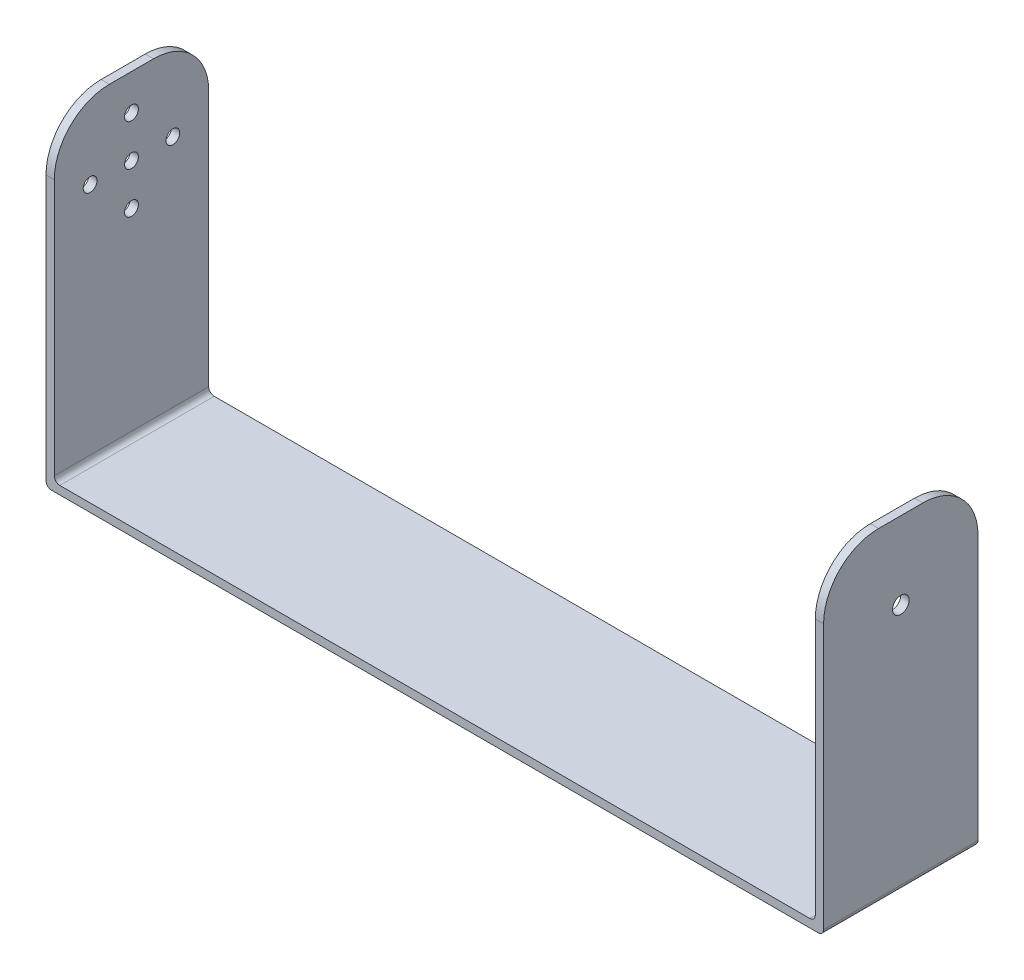
from build123d import *

# Parameters (mm, degrees)
SKETCH1_W               = 138
SKETCH1_H               = 28
BOSS_EXTRUDE1_DEPTH     = 1.5
SKETCH2_W               = 28
SKETCH2_H               = 59
BOSS_EXTRUDE2_DEPTH     = 1.5
FILLET1_R               = 1
FILLET2_R               = 1
FILLET5_R               = 10
SKETCH3_R               = 1.25
CUT_EXTRUDE1_DEPTH      = 15
CUT_EXTRUDE1_DEPTH_BACK = 15
SKETCH4_W               = 28
SKETCH4_H               = 59
BOSS_EXTRUDE3_DEPTH     = 1.5
FILLET6_R               = 1
FILLET7_R               = 1
SKETCH5_R               = 1.5
CUT_EXTRUDE3_DEPTH      = 1.5
CUT_EXTRUDE3_DEPTH_BACK = 31.5
FILLET10_R              = 10
FILLET11_R              = 10


with BuildPart() as part:
    # Sketch1 → Boss-Extrude1 (new body)
    with BuildSketch(Plane(origin=(0, 0, 0), x_dir=(1, 0, 0), z_dir=(0, 1, 0))):
        with Locations((69, 14)):
            Rectangle(SKETCH1_W, SKETCH1_H)
    extrude(amount=BOSS_EXTRUDE1_DEPTH)

    # Sketch2 → Boss-Extrude2 (add)
    with BuildSketch(Plane(origin=(0, 0, 0), x_dir=(0, 0, -1), z_dir=(1, 0, 0))):
        with Locations((14, 29.5)):
            Rectangle(SKETCH2_W, SKETCH2_H)
    extrude(amount=-BOSS_EXTRUDE2_DEPTH)

    # Fillet1
    fillet1_edges = [part.edges().sort_by_distance(p)[0] for p in [
        (0, 1.5, -14),
    ]]
    fillet(fillet1_edges, radius=FILLET1_R)

    # Fillet2
    fillet2_edges = [part.edges().sort_by_distance(p)[0] for p in [
        (-1.5, 0, -14),
    ]]
    fillet(fillet2_edges, radius=FILLET2_R)

    # Fillet5
    fillet5_edges = [part.edges().sort_by_distance(p)[0] for p in [
        (-0.75, 59, 0),
        (-0.75, 59, -28),
    ]]
    fillet(fillet5_edges, radius=FILLET5_R)

    # Sketch3 → Cut-Extrude1 (cut, two sides)
    with BuildSketch(Plane(origin=(0, 0, 0), x_dir=(0, 0, -1), z_dir=(1, 0, 0))) as cut_extrude1_sk:
        with Locations((14, 52.5)):
            Circle(SKETCH3_R)
        with Locations((6.5, 45)):
            Circle(SKETCH3_R)
        with Locations((14, 45)):
            Circle(SKETCH3_R)
        with Locations((21.5, 45)):
            Circle(SKETCH3_R)
        with Locations((14, 37.5)):
            Circle(SKETCH3_R)
    extrude(amount=CUT_EXTRUDE1_DEPTH, mode=Mode.SUBTRACT)
    extrude(cut_extrude1_sk.sketch, amount=-CUT_EXTRUDE1_DEPTH_BACK, mode=Mode.SUBTRACT)

    # Sketch4 → Boss-Extrude3 (add)
    with BuildSketch(Plane(origin=(138, 0, 0), x_dir=(0, 0, -1), z_dir=(1, 0, 0))):
        with Locations((14, 29.5)):
            Rectangle(SKETCH4_W, SKETCH4_H)
    extrude(amount=BOSS_EXTRUDE3_DEPTH)

    # Fillet6
    fillet6_edges = [part.edges().sort_by_distance(p)[0] for p in [
        (139.5, 0, -14),
    ]]
    fillet(fillet6_edges, radius=FILLET6_R)

    # Fillet7
    fillet7_edges = [part.edges().sort_by_distance(p)[0] for p in [
        (138, 1.5, -14),
    ]]
    fillet(fillet7_edges, radius=FILLET7_R)

    # Sketch5 → Cut-Extrude3 (cut, two sides)
    with BuildSketch(Plane(origin=(139.5, 0, 0), x_dir=(0, 0, -1), z_dir=(1, 0, 0))) as cut_extrude3_sk:
        with Locations((14, 45)):
            Circle(SKETCH5_R)
    extrude(amount=CUT_EXTRUDE3_DEPTH, mode=Mode.SUBTRACT)
    extrude(cut_extrude3_sk.sketch, amount=-CUT_EXTRUDE3_DEPTH_BACK, mode=Mode.SUBTRACT)

    # Fillet10
    fillet10_edges = [part.edges().sort_by_distance(p)[0] for p in [
        (138.75, 59, -28),
    ]]
    fillet(fillet10_edges, radius=FILLET10_R)

    # Fillet11
    fillet11_edges = [part.edges().sort_by_distance(p)[0] for p in [
        (138.75, 59, 0),
    ]]
    fillet(fillet11_edges, radius=FILLET11_R)


solid = part.part
